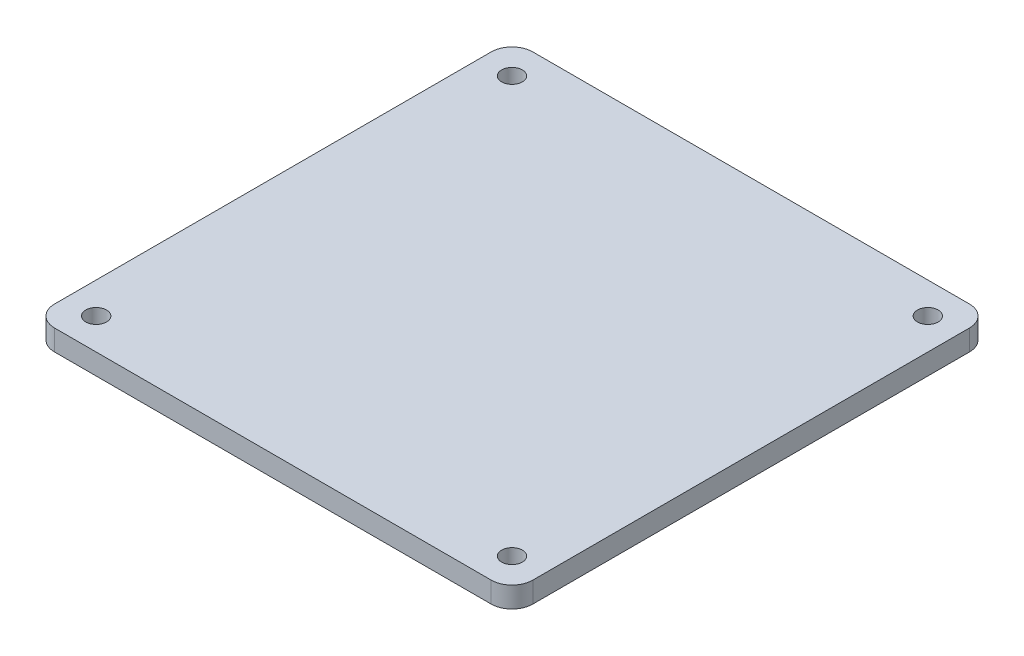
from build123d import *

# Parameters (mm, degrees)
SKETCH1_R           = 1
BOSS_EXTRUDE1_DEPTH = 2


with BuildPart() as part:
    # Sketch1 → Boss-Extrude1 (new body)
    with BuildSketch(Plane(origin=(0, 0, 0), x_dir=(1, 0, 0), z_dir=(0, 1, 0))):
        with BuildLine():
            Line((-21, 23), (21, 23))
            ThreePointArc((21, 23), (22.414213562, 22.414213562), (23, 21))
            Line((23, 21), (23, -21))
            ThreePointArc((23, -21), (22.414213562, -22.414213562), (21, -23))
            Line((21, -23), (-21, -23))
            ThreePointArc((-21, -23), (-22.414213562, -22.414213562), (-23, -21))
            Line((-23, -21), (-23, 21))
            ThreePointArc((-23, 21), (-22.414213562, 22.414213562), (-21, 23))
        make_face()
        with Locations((-20, 20)):
            Circle(SKETCH1_R, mode=Mode.SUBTRACT)
        with Locations((20, 20)):
            Circle(SKETCH1_R, mode=Mode.SUBTRACT)
        with Locations((-20, -20)):
            Circle(SKETCH1_R, mode=Mode.SUBTRACT)
        with Locations((20, -20)):
            Circle(SKETCH1_R, mode=Mode.SUBTRACT)
    extrude(amount=BOSS_EXTRUDE1_DEPTH)


solid = part.part
